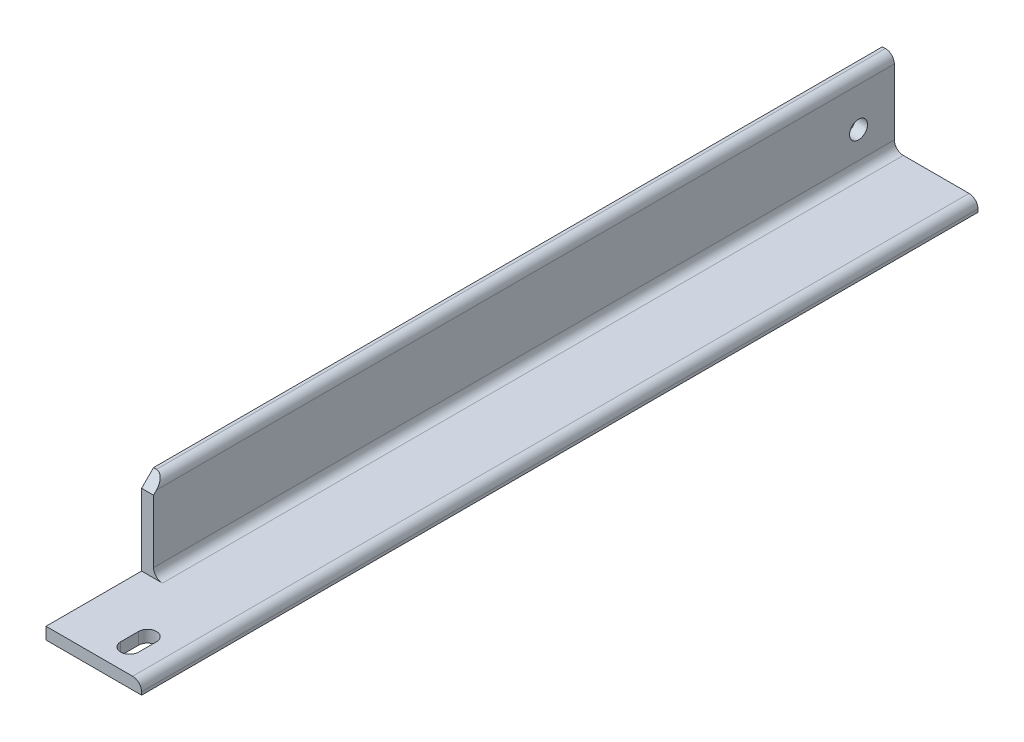
from build123d import *

# Parameters (mm, degrees)
BOSS_EXTRUDE1_DEPTH             = 444.5
CUT_EXTRUDE4_REACH              = 103.6
CUT_EXTRUDE2_REACH              = 103.6
F_3_4_0_75_DIAMETER_HOLE2_D     = 19.05
F_3_4_0_75_DIAMETER_HOLE2_DEPTH = 12.7


with BuildPart() as part:
    # Sketch1 → Boss-Extrude1 (new body, symmetric)
    with BuildSketch(Plane.XY):
        with BuildLine():
            Line((0, 0), (0, 101.6))
            Line((0, 101.6), (3.18008, 101.6))
            ThreePointArc((3.18008, 101.6), (9.911679988, 98.811679988), (12.7, 92.08008))
            Line((12.7, 92.08008), (12.7, 22.225))
            ThreePointArc((12.7, 22.225), (15.489807909, 15.489807909), (22.225, 12.7))
            Line((22.225, 12.7), (92.08008, 12.7))
            ThreePointArc((92.08008, 12.7), (98.811679988, 9.911679988), (101.6, 3.18008))
            Line((101.6, 3.18008), (101.6, 0))
            Line((101.6, 0), (0, 0))
        make_face()
    extrude(amount=BOSS_EXTRUDE1_DEPTH, both=True)

    # Sketch2 → Cut-Extrude4 (cut, up to next)
    with BuildSketch(Plane.YZ, mode=Mode.PRIVATE) as cut_extrude4_sk1:
        Polygon((12.7, 444.5), (12.7, 342.9), (88.9, 342.9), (101.6, 330.2), (101.6, 342.9), (101.6, 444.5), align=None)
    cut_extrude4_tool1 = extrude(cut_extrude4_sk1.sketch, amount=CUT_EXTRUDE4_REACH, mode=Mode.PRIVATE) & part.part
    add(cut_extrude4_tool1.solids().sort_by_distance((0, 57.5059, 393.212979))[0], mode=Mode.SUBTRACT)

    # Sketch3 → Cut-Extrude2 (cut, up to next)
    with BuildSketch(Plane.ZX, mode=Mode.PRIVATE) as cut_extrude2_sk1:
        with BuildLine():
            Line((419.1, 53.975), (400.05, 53.975))
            ThreePointArc((400.05, 53.975), (390.525, 63.5), (400.05, 73.025))
            Line((400.05, 73.025), (419.1, 73.025))
            ThreePointArc((419.1, 73.025), (428.625, 63.5), (419.1, 53.975))
        make_face()
    cut_extrude2_tool1 = extrude(cut_extrude2_sk1.sketch, amount=CUT_EXTRUDE2_REACH, mode=Mode.PRIVATE) & part.part
    add(cut_extrude2_tool1.solids().sort_by_distance((63.5, 0, 409.575))[0], mode=Mode.SUBTRACT)

    # 3/4 (0.75) Diameter Hole2
    with Locations(Plane.ZY):
        with Locations((-406.4, 50.8)):
            Hole(F_3_4_0_75_DIAMETER_HOLE2_D / 2, depth=F_3_4_0_75_DIAMETER_HOLE2_DEPTH)


solid = part.part
